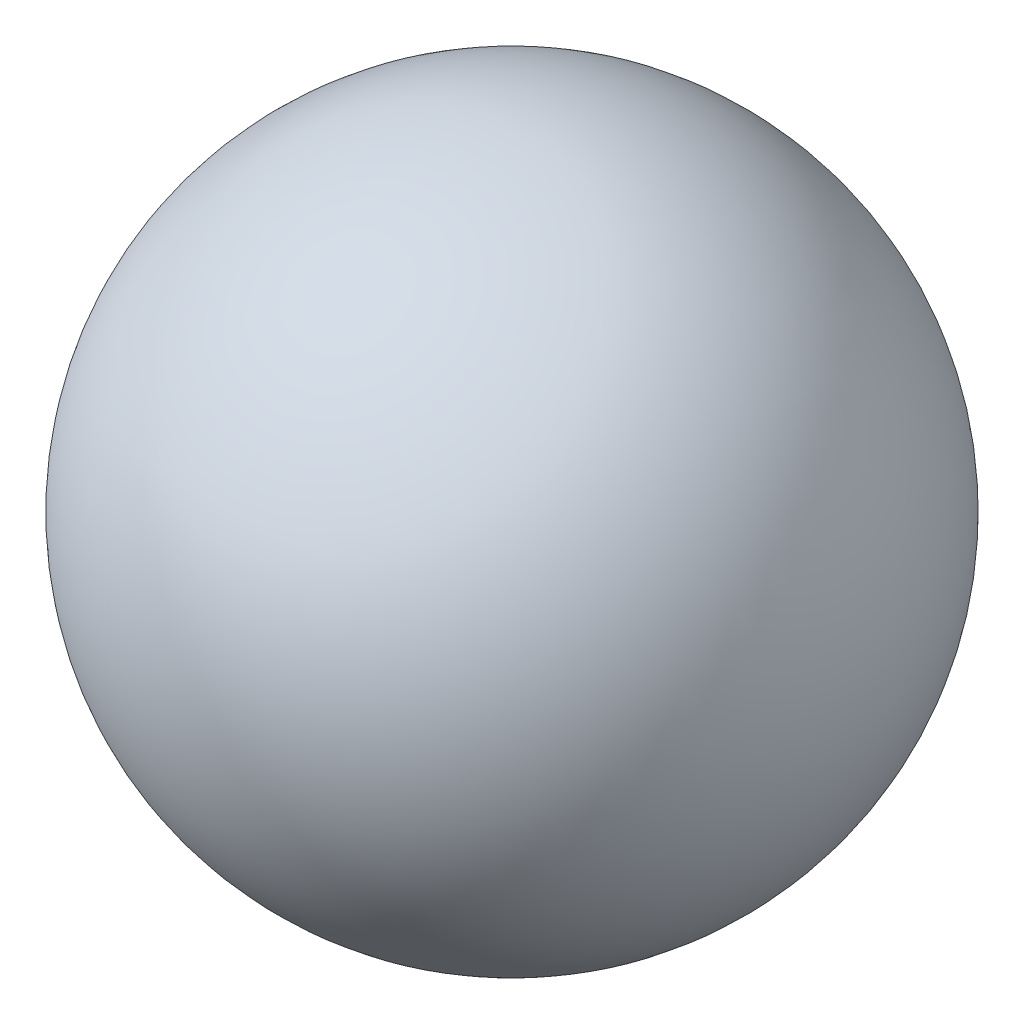
from build123d import *


with BuildPart() as part:
    # Sketch1 → Revolve1 (revolve)
    with BuildSketch(Plane.XY):
        with BuildLine():
            Line((0, 200), (0, 0))
            ThreePointArc((0, 0), (100, 100), (0, 200))
        make_face()
    revolve(axis=Axis((0, 0, 0), (0, 1, 0)))


solid = part.part
